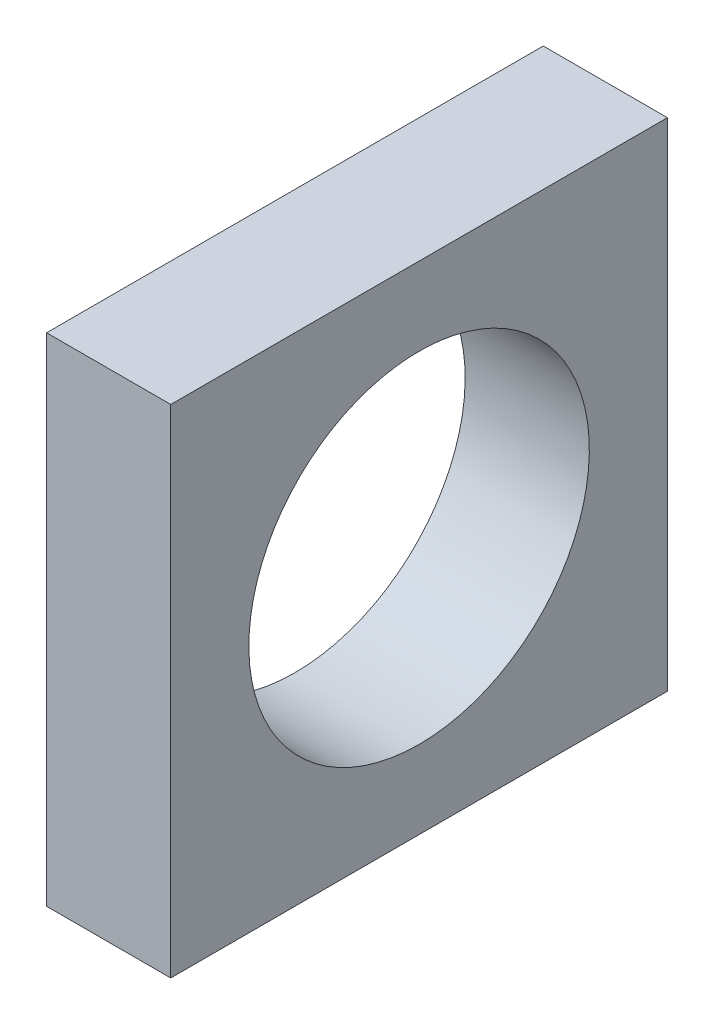
from build123d import *

# Parameters (mm, degrees)
SKETCH1_W           = 6.35
SKETCH1_H           = 25.4
BOSS_EXTRUDE1_DEPTH = 25.4
SKETCH4_R           = 6.441586538
CUT_EXTRUDE1_DEPTH  = 6.35
CUT_EXTRUDE2_REACH  = 8.35
SKETCH3_R           = 8.70585


with BuildPart() as part:
    # Sketch1 → Boss-Extrude1 (new body)
    with BuildSketch(Plane.XY):
        with Locations((8.322674216, -16.049389649)):
            Rectangle(SKETCH1_W, SKETCH1_H)
    extrude(amount=BOSS_EXTRUDE1_DEPTH)

    # Sketch4 → Cut-Extrude1 (cut)
    with BuildSketch(Plane.ZY.offset(-5.147674216)):
        with Locations((12.7, -16.049389649)):
            Circle(SKETCH4_R)
    extrude(amount=-CUT_EXTRUDE1_DEPTH, mode=Mode.SUBTRACT)

    # Sketch3 → Cut-Extrude2 (cut, up to next)
    with BuildSketch(Plane.ZY.offset(-5.147674216), mode=Mode.PRIVATE) as cut_extrude2_sk1:
        with Locations((12.7, -16.049389649)):
            Circle(SKETCH3_R)
    cut_extrude2_tool1 = extrude(cut_extrude2_sk1.sketch, amount=-CUT_EXTRUDE2_REACH, mode=Mode.PRIVATE) & part.part
    add(cut_extrude2_tool1.solids().sort_by_distance((5.147674, -16.04939, 12.7))[0], mode=Mode.SUBTRACT)


solid = part.part
